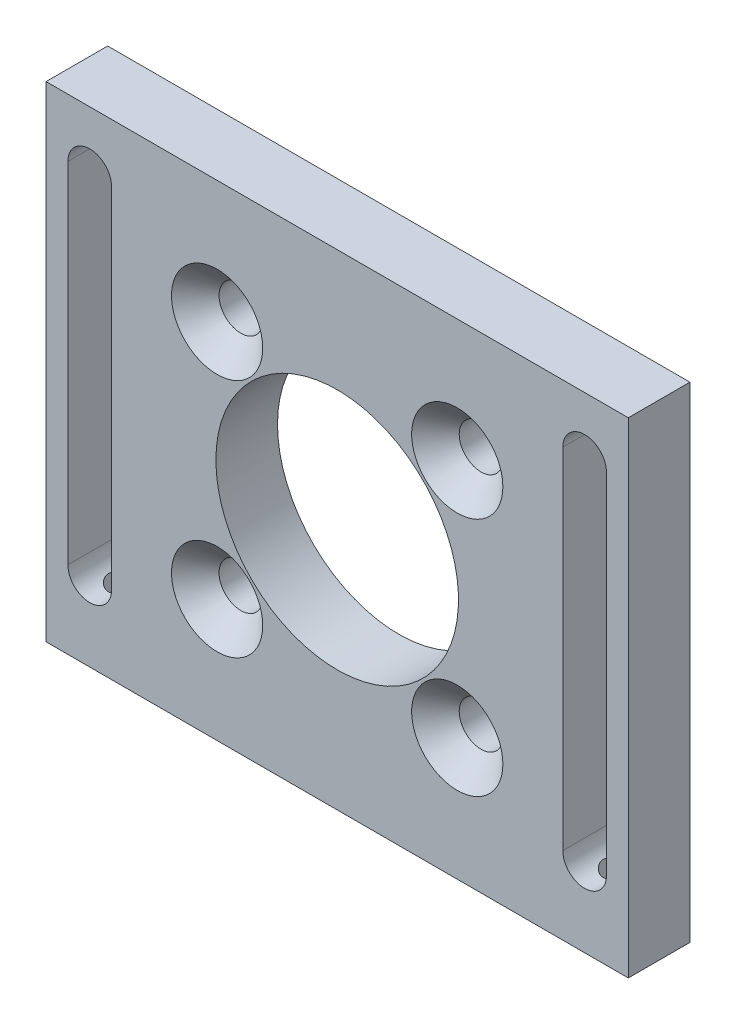
from build123d import *

# Parameters (mm, degrees)
SKETCH1_W                  = 60
SKETCH1_H                  = 50
BOSS_EXTRUDE1_DEPTH        = 6.35
CUT_EXTRUDE1_DEPTH         = 40.564156758
CUT_EXTRUDE2_DEPTH         = 40.564156758
HOLE1_D                    = 25
F_2_CLEARANCE_HOLE1_REACH  = 60.654
F_2_CLEARANCE_HOLE1_BORE_R = 1.25
F_8_CLEARANCE_HOLE1_D      = 4.499991
CHAMFER1_SIZE              = 2.449999926


with BuildPart() as part:
    # Sketch1 → Boss-Extrude1 (new body)
    with BuildSketch(Plane(origin=(0, 0, 0), x_dir=(-1, 0, 0), z_dir=(0, 0, -1))):
        Rectangle(SKETCH1_W, SKETCH1_H)
    extrude(amount=-BOSS_EXTRUDE1_DEPTH)

    # Sketch2 → Cut-Extrude1 (cut, through all)
    with BuildSketch(Plane(origin=(0, 0, 0), x_dir=(-1, 0, 0), z_dir=(0, 0, -1))):
        with BuildLine():
            Line((23.25, 19), (23.25, -17))
            ThreePointArc((23.25, -17), (25.5, -19.25), (27.75, -17))
            Line((27.75, -17), (27.75, 19))
            ThreePointArc((27.75, 19), (25.5, 21.25), (23.25, 19))
        make_face()
    extrude(amount=-CUT_EXTRUDE1_DEPTH, mode=Mode.SUBTRACT)

    # Sketch3 → Cut-Extrude2 (cut, through all)
    with BuildSketch(Plane.XY.offset(6.35)):
        with BuildLine():
            Line((27.75, -17), (27.75, 19))
            ThreePointArc((27.75, 19), (25.5, 21.25), (23.25, 19))
            Line((23.25, 19), (23.25, -17))
            ThreePointArc((23.25, -17), (25.5, -19.25), (27.75, -17))
        make_face()
    extrude(amount=-CUT_EXTRUDE2_DEPTH, mode=Mode.SUBTRACT)

    # Hole1 (through all)
    with Locations(Plane(origin=(0, 0, 0), x_dir=(-1, 0, 0), z_dir=(0, 0, -1))):
        with Locations((0, 0)):
            Hole(HOLE1_D / 2)

    # #2 Clearance Hole1 bore → #2 Clearance Hole1 (cut, up to next)
    with BuildSketch(Plane(origin=(0, -25, 0), x_dir=(-1, 0, 0), z_dir=(0, -1, 0)), mode=Mode.PRIVATE) as f_2_clearance_hole1_sk1:
        with Locations((-25.5, -3.175)):
            Circle(F_2_CLEARANCE_HOLE1_BORE_R)
    f_2_clearance_hole1_tool1 = extrude(f_2_clearance_hole1_sk1.sketch, amount=-F_2_CLEARANCE_HOLE1_REACH, mode=Mode.PRIVATE) & part.part
    # #2 Clearance Hole1 bore → #2 Clearance Hole1 (cut, up to next)
    with BuildSketch(Plane(origin=(0, -25, 0), x_dir=(-1, 0, 0), z_dir=(0, -1, 0)), mode=Mode.PRIVATE) as f_2_clearance_hole1_sk2:
        with Locations((25.5, -3.175)):
            Circle(F_2_CLEARANCE_HOLE1_BORE_R)
    f_2_clearance_hole1_tool2 = extrude(f_2_clearance_hole1_sk2.sketch, amount=-F_2_CLEARANCE_HOLE1_REACH, mode=Mode.PRIVATE) & part.part
    add(f_2_clearance_hole1_tool1.solids().sort_by_distance((25.5, -25, 3.175))[0], mode=Mode.SUBTRACT)
    add(f_2_clearance_hole1_tool2.solids().sort_by_distance((-25.5, -25, 3.175))[0], mode=Mode.SUBTRACT)

    # #8 Clearance Hole1 (through all)
    with Locations(Plane(origin=(0, 0, 0), x_dir=(-1, 0, 0), z_dir=(0, 0, -1))):
        with Locations((-12.374368671, 12.374368671), (-12.374368671, -12.374368671), (12.374368671, -12.374368671), (12.374368671, 12.374368671)):
            Hole(F_8_CLEARANCE_HOLE1_D / 2)

    # Chamfer1
    chamfer1_edges = [part.edges().sort_by_distance(p)[0] for p in [
        (-14.624364171, 12.374368671, 6.35),
        (-14.624364171, -12.374368671, 6.35),
        (10.124373171, -12.374368671, 6.35),
        (10.124373171, 12.374368671, 6.35),
    ]]
    chamfer(chamfer1_edges, length=CHAMFER1_SIZE)


solid = part.part
